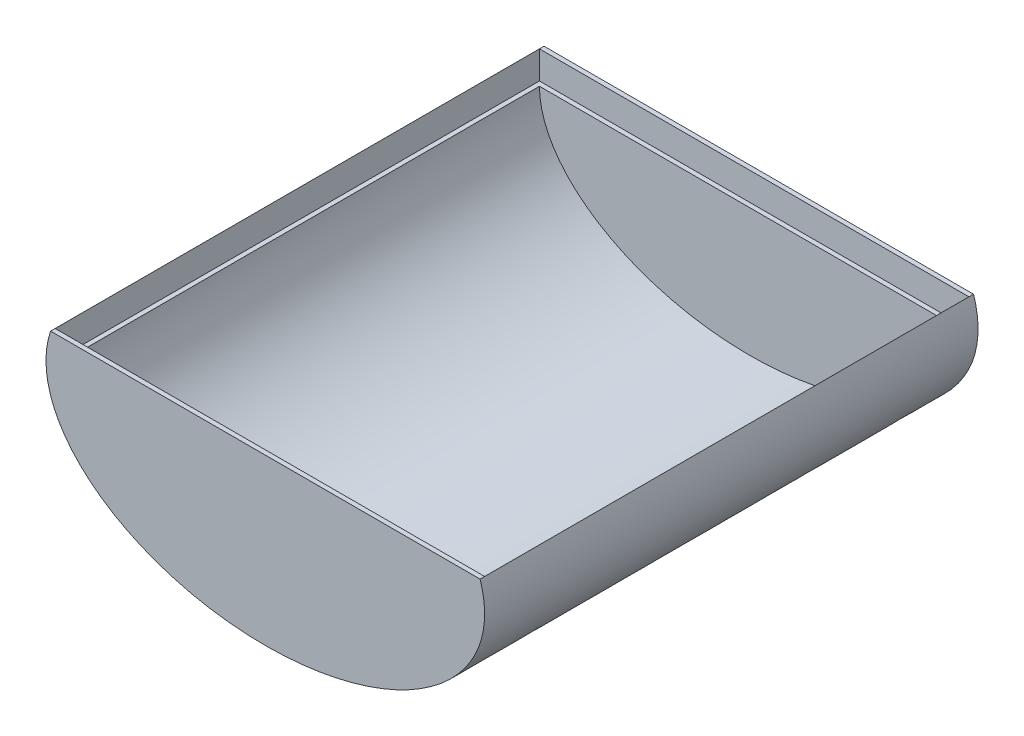
from build123d import *

# Parameters (mm, degrees)
SKETCH1_RX              = 15.24
SKETCH1_RY              = 9.525
BOSS_EXTRUDE2_DEPTH     = 34.29
CUT_EXTRUDE1_START      = -0.635
SKETCH3_RX              = 14.605
SKETCH3_RY              = 8.89
CUT_EXTRUDE1_DEPTH      = 33.02
CUT_EXTRUDE3_START      = -0.635
CUT_EXTRUDE3_DEPTH      = 32.7025
SKETCH6_W               = 32.06646649
SKETCH6_H               = 9.119465297
CUT_EXTRUDE4_DEPTH      = 40.3225
CUT_EXTRUDE4_DEPTH_BACK = 32.7025
SKETCH7_W               = 29.517013218
SKETCH7_H               = 33.655
CUT_EXTRUDE5_DEPTH      = 1.93413
SKETCH8_W               = 0.327986782
SKETCH8_H               = 0.3175
CUT_EXTRUDE6_DEPTH      = 1.93413
SKETCH9_W               = 0.327986782
SKETCH9_H               = 0.635
CUT_EXTRUDE7_DEPTH      = 1.93413


with BuildPart() as part:
    # Sketch1 → Boss-Extrude2 (new body)
    with BuildSketch(Plane.XY):
        with Locations(Location((0, 0), (0, 0, 180))):
            Ellipse(SKETCH1_RX, SKETCH1_RY)
    extrude(amount=BOSS_EXTRUDE2_DEPTH)

    # Sketch3 → Cut-Extrude1 (cut)
    with BuildSketch(Plane.XY.offset(34.29).offset(CUT_EXTRUDE1_START)):
        with Locations(Location((0, 0), (0, 0, 4.189e-06))):
            Ellipse(SKETCH3_RX, SKETCH3_RY)
    extrude(amount=-CUT_EXTRUDE1_DEPTH, mode=Mode.SUBTRACT)

    # Sketch4 → Cut-Extrude3 (cut)
    with BuildSketch(Plane.XY.offset(34.29).offset(CUT_EXTRUDE3_START)):
        with BuildLine():
            Line((-14.9225, 0), (0, 0))
            Line((0, 0), (0, 9.525))
            add(Edge.make_bspline(
                [(0, 9.525), (-12.403805408, 9.525), (-14.9225, 1.934129503)],
                knots=[4.71238898, 4.71238898, 4.71238898, 6.078705108, 6.078705108, 6.078705108], degree=2, weights=[1, 0.775583076, 1]))
            Line((-14.9225, 1.934129503), (-14.9225, 0))
        make_face()
        with BuildLine():
            Line((0, 0), (14.9225, 0))
            Line((14.9225, 0), (14.9225, 1.934129503))
            add(Edge.make_bspline(
                [(14.9225, 1.934129503), (12.403805408, 9.525), (0, 9.525)],
                knots=[3.346072853, 3.346072853, 3.346072853, 4.71238898, 4.71238898, 4.71238898], degree=2, weights=[1, 0.775583076, 1]))
            Line((0, 9.525), (0, 0))
        make_face()
    extrude(amount=-CUT_EXTRUDE3_DEPTH, mode=Mode.SUBTRACT)

    # Sketch6 → Cut-Extrude4 (cut, two sides)
    with BuildSketch(Plane(origin=(0, 0, 33.655), x_dir=(-1, 0, 0), z_dir=(0, 0, -1))) as cut_extrude4_sk:
        with Locations((1.110733245, 6.493862152)):
            Rectangle(SKETCH6_W, SKETCH6_H)
    extrude(amount=CUT_EXTRUDE4_DEPTH, mode=Mode.SUBTRACT)
    extrude(cut_extrude4_sk.sketch, amount=-CUT_EXTRUDE4_DEPTH_BACK, mode=Mode.SUBTRACT)

    # Sketch7 → Cut-Extrude5 (cut)
    with BuildSketch(Plane(origin=(0, 1.934129503, 0), x_dir=(1, 0, 0), z_dir=(0, 1, 0))):
        with Locations((0.163993391, -17.145)):
            Rectangle(SKETCH7_W, SKETCH7_H)
    extrude(amount=-CUT_EXTRUDE5_DEPTH, mode=Mode.SUBTRACT)

    # Sketch8 → Cut-Extrude6 (cut)
    with BuildSketch(Plane(origin=(0, 1.934129503, 0), x_dir=(1, 0, 0), z_dir=(0, 1, 0))):
        with Locations((-14.758506609, -33.81375)):
            Rectangle(SKETCH8_W, SKETCH8_H)
    extrude(amount=-CUT_EXTRUDE6_DEPTH, mode=Mode.SUBTRACT)

    # Sketch9 → Cut-Extrude7 (cut)
    with BuildSketch(Plane(origin=(0, 1.934129503, 0), x_dir=(1, 0, 0), z_dir=(0, 1, 0))):
        with Locations((-14.758506609, -0.635)):
            Rectangle(SKETCH9_W, SKETCH9_H)
    extrude(amount=-CUT_EXTRUDE7_DEPTH, mode=Mode.SUBTRACT)


solid = part.part
